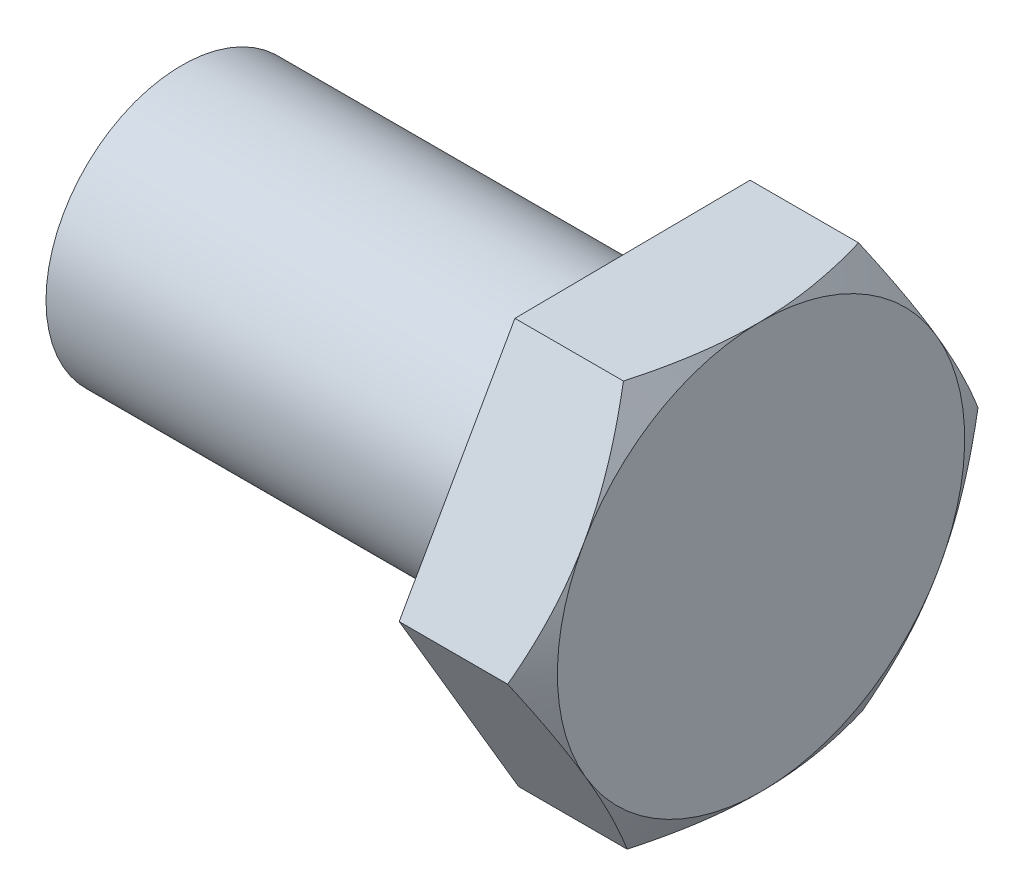
from build123d import *

# Parameters (mm, degrees)
BOSS_EXTRUDE1_DEPTH = 8.89
SKETCH2_OUTSIDE_W   = 61.52
SKETCH2_OUTSIDE_H   = 57.248
SKETCH2_OUTSIDE_R   = 14.2875
CUT_EXTRUDE1_DEPTH  = 5.08
CUT_EXTRUDE1_TAPER  = 60
SKETCH3_R           = 9.525
BOSS_EXTRUDE2_DEPTH = 31.75


with BuildPart() as part:
    # Sketch1 → Boss-Extrude1 (new body)
    with BuildSketch(Plane(origin=(0, 0, 0), x_dir=(0, 0, -1), z_dir=(1, 0, 0))):
        Polygon((8.377045531, -14.212740171), (16.497116811, 0.148364153), (8.12007128, 14.361104324), (-8.377045531, 14.212740171), (-16.497116811, -0.148364153), (-8.12007128, -14.361104324), align=None)
    extrude(amount=BOSS_EXTRUDE1_DEPTH)

    # Sketch2 outside → Cut-Extrude1 (cut)
    with BuildSketch(Plane(origin=(8.89, 0, 0), x_dir=(0, 0, -1), z_dir=(1, 0, 0))):
        Rectangle(SKETCH2_OUTSIDE_W, SKETCH2_OUTSIDE_H)
        Circle(SKETCH2_OUTSIDE_R, mode=Mode.SUBTRACT)
    extrude(amount=-CUT_EXTRUDE1_DEPTH, taper=CUT_EXTRUDE1_TAPER, mode=Mode.SUBTRACT)

    # Sketch3 → Boss-Extrude2 (add)
    with BuildSketch(Plane.ZY):
        Circle(SKETCH3_R)
    extrude(amount=BOSS_EXTRUDE2_DEPTH)


solid = part.part
